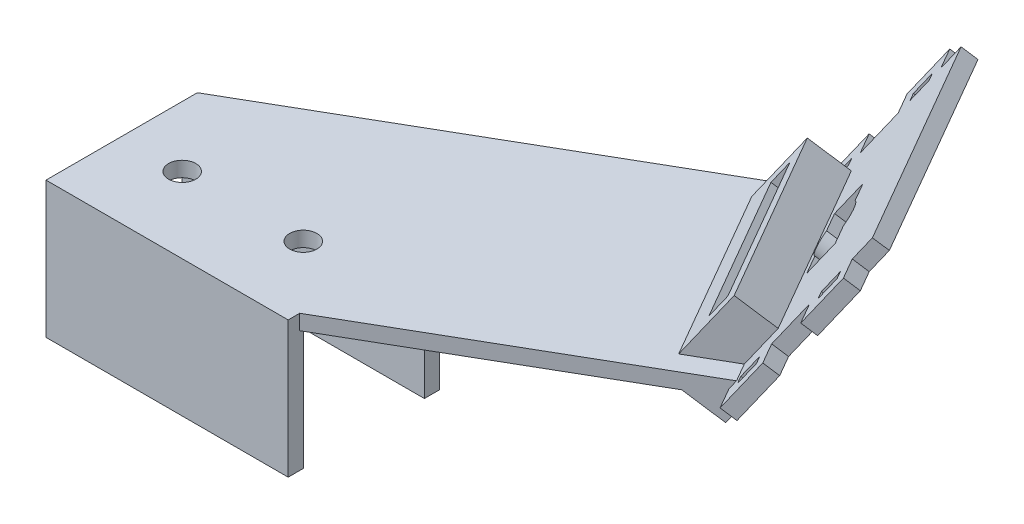
from build123d import *

# Parameters (mm, degrees)
BOSS_EXTRUDE1_DEPTH  = 50.8
SKETCH3_R            = 2.8575
CUT_EXTRUDE1_DEPTH   = 29.575
BOSS_EXTRUDE2_DEPTH  = 3.175
BOSS_EXTRUDE4_DEPTH  = 50.8
CUT_EXTRUDE2_REACH   = 108.711
BOSS_EXTRUDE5_DEPTH  = 8.255
BOSS_EXTRUDE6_REACH  = 116.966
CUT_EXTRUDE3_DEPTH   = 8.255
BOSS_EXTRUDE10_DEPTH = 3.175
BOSS_EXTRUDE11_DEPTH = 8.255
CUT_EXTRUDE4_START   = -11.43
CUT_EXTRUDE4_DEPTH   = 8.255
BOSS_EXTRUDE12_DEPTH = 4.445
CUT_EXTRUDE5_DEPTH   = 4.445
BOSS_EXTRUDE13_START = -50.8
BOSS_EXTRUDE13_DEPTH = 4.445
CUT_EXTRUDE6_START   = -50.8
CUT_EXTRUDE6_DEPTH   = 4.445
SKETCH18_R           = 5.08
CUT_EXTRUDE7_DEPTH   = 55.801163899


with BuildPart() as part:
    # Sketch2 → Boss-Extrude1 (new body)
    with BuildSketch(Plane(origin=(0, 0, 0), x_dir=(0, 0, -1), z_dir=(1, 0, 0))):
        Polygon((0, 0), (31.75, 0), (31.75, -28.575), (28.575, -28.575), (28.575, -3.175), (3.175, -3.175), (3.175, -28.575), (0, -28.575), align=None)
    extrude(amount=BOSS_EXTRUDE1_DEPTH)

    # Sketch3 → Cut-Extrude1 (cut, through all)
    with BuildSketch(Plane(origin=(0, 0, 0), x_dir=(1, 0, 0), z_dir=(0, 1, 0))):
        with Locations((12.7, 15.875)):
            Circle(SKETCH3_R)
        with Locations((38.1, 15.875)):
            Circle(SKETCH3_R)
    extrude(amount=-CUT_EXTRUDE1_DEPTH, mode=Mode.SUBTRACT)

    # Sketch4 → Boss-Extrude2 (add)
    with BuildSketch(Plane(origin=(0, 0, 0), x_dir=(1, 0, 0), z_dir=(0, 1, 0))):
        Polygon((0, 31.75), (76.2, 75.744090512), (101.6, 31.75), (50.8, 2.420606325), (50.8, 31.75), align=None)
    extrude(amount=-BOSS_EXTRUDE2_DEPTH)

    # Sketch6 → Boss-Extrude4 (add)
    with BuildSketch(Plane(origin=(-13.748153285, 0, -23.8125), x_dir=(-0.866025404, 0, 0.5), z_dir=(-0.5, 0, -0.866025404))):
        Polygon((-103.863181024, -3.175), (-128.994432583, 32.716146821), (-126.393624843, 34.537252006), (-102.210380639, 0), (-103.863181024, 0), align=None)
    extrude(amount=-BOSS_EXTRUDE4_DEPTH)

    # Sketch7 → Cut-Extrude2 (cut, up to next)
    with BuildSketch(Plane(origin=(61.648020601, -49.844275413, -35.592501289), x_dir=(-0.318495595, 0.25751325, -0.91227599), z_dir=(0.70940648, -0.573576436, -0.409576022)), mode=Mode.PRIVATE) as cut_extrude2_sk1:
        Polygon((20.449889648, 80.334208308), (35.520058582, 75.3436539), (33.124592466, 68.109972811), (18.054423532, 73.100527219), align=None)
    cut_extrude2_tool1 = extrude(cut_extrude2_sk1.sketch, amount=-CUT_EXTRUDE2_REACH, mode=Mode.PRIVATE) & part.part
    add(cut_extrude2_tool1.solids().sort_by_distance((99.782151, 14.770573, -60.029858))[0], mode=Mode.SUBTRACT)
    # Sketch7 → Cut-Extrude2 (cut, up to next)
    with BuildSketch(Plane(origin=(61.648020601, -49.844275413, -35.592501289), x_dir=(-0.318495595, 0.25751325, -0.91227599), z_dir=(0.70940648, -0.573576436, -0.409576022)), mode=Mode.PRIVATE) as cut_extrude2_sk2:
        Polygon((7.213752471, 71.673620272), (40.970930883, 60.494778398), (39.373953472, 55.672324339), (5.61677506, 66.851166213), align=None)
    cut_extrude2_tool2 = extrude(cut_extrude2_sk2.sketch, amount=-CUT_EXTRUDE2_REACH, mode=Mode.PRIVATE) & part.part
    add(cut_extrude2_tool2.solids().sort_by_distance((94.262219, 5.667746, -56.842924))[0], mode=Mode.SUBTRACT)

    # Sketch8 → Boss-Extrude5 (add)
    with BuildSketch(Plane(origin=(61.648020601, -49.844275413, -35.592501289), x_dir=(-0.318495595, 0.25751325, -0.91227599), z_dir=(0.70940648, -0.573576436, -0.409576022))):
        Polygon((-4.21199432, 61.410144483), (44.012546269, 45.440370378), (57.786476434, 87.034036636), (9.561935845, 103.003810741), align=None)
        Polygon((11.577858751, 98.991666073), (-0.199849652, 63.426067388), (41.996623363, 49.452515046), (53.774331766, 85.018113731), align=None, mode=Mode.SUBTRACT)
    extrude(amount=BOSS_EXTRUDE5_DEPTH)

    # Boss-Extrude6: up to this face of the body (flat: up to its plane)
    boss_extrude6_end = Plane(part.part.faces().sort_by_distance((50.815624122, -3.175, -33.129894289))[0])
    # Sketch9 → Boss-Extrude6 (add, up to the picked face)
    with BuildSketch(Plane(origin=(67.504171093, -54.579148895, -38.973551352), x_dir=(-0.318495595, 0.25751325, -0.91227599), z_dir=(0.70940648, -0.573576436, -0.409576022)), mode=Mode.PRIVATE) as boss_extrude6_sk1:
        Polygon((0.007652981, 60.012789249), (39.792898967, 46.837725612), (38.994410262, 44.426498583), (-0.790835724, 57.601562219), align=None)
    boss_extrude6_tool1 = split(extrude(boss_extrude6_sk1.sketch, amount=-BOSS_EXTRUDE6_REACH, mode=Mode.PRIVATE), bisect_by=boss_extrude6_end, keep=Keep.BOTH, mode=Mode.PRIVATE)
    add(boss_extrude6_tool1.solids().sort_by_distance((94.125301, -8.950197, -56.763874))[0])

    # Sketch10 → Cut-Extrude3 (cut)
    with BuildSketch(Plane(origin=(67.504171093, -54.579148895, -38.973551352), x_dir=(-0.318495595, 0.25751325, -0.91227599), z_dir=(0.70940648, -0.573576436, -0.409576022))):
        Polygon((4.019797649, 62.028712154), (37.776976062, 50.84987028), (36.978487357, 48.438643251), (3.221308944, 59.617485125), align=None)
    extrude(amount=-CUT_EXTRUDE3_DEPTH, mode=Mode.SUBTRACT)

    # Sketch14 → Boss-Extrude10 (add)
    with BuildSketch(Plane(origin=(67.504171093, -54.579148895, -38.973551352), x_dir=(-0.318495595, 0.25751325, -0.91227599), z_dir=(0.70940648, -0.573576436, -0.409576022))):
        Polygon((-2.515205822, 66.534001921), (-7.337659881, 68.130979331), (-3.744460707, 78.981500964), (1.077993352, 77.384523553), (0.07988247, 74.370489766), (-1.728537802, 74.969356295), (-3.325515212, 70.146902236), (-1.51709494, 69.548035707), align=None)
        Polygon((5.058616193, 95.464786046), (6.867036465, 94.865919517), (7.865147347, 97.879953304), (3.042693288, 99.476930714), (-0.550505886, 88.626409082), (4.271948173, 87.029431671), (5.270059055, 90.043465458), (3.461638782, 90.642331987), align=None)
        Polygon((55.303019916, 73.474824824), (56.899997326, 78.297278883), (55.091577054, 78.896145411), (56.089687936, 81.910179198), (60.912141995, 80.313201788), (57.318942821, 69.462680155), (52.496488762, 71.059657566), (53.494599644, 74.073691353), align=None)
        Polygon((48.515865921, 52.979395073), (46.707445649, 53.578261602), (45.709334767, 50.564227815), (50.531788826, 48.967250405), (54.124988, 59.817772037), (49.302533941, 61.414749448), (48.304423059, 58.400715661), (50.112843331, 57.801849132), align=None)
    extrude(amount=-BOSS_EXTRUDE10_DEPTH)

    # Sketch15 → Boss-Extrude11 (add)
    with BuildSketch(Plane(origin=(61.648020601, -49.844275413, -35.592501289), x_dir=(-0.318495595, 0.25751325, -0.91227599), z_dir=(0.70940648, -0.573576436, -0.409576022))):
        Polygon((4.019797649, 62.028712154), (7.213752471, 71.673620272), (40.970930883, 60.494778398), (37.776976062, 50.84987028), (41.996623363, 49.452515046), (53.774331766, 85.018113731), (11.577858751, 98.991666073), (-0.199849652, 63.426067388), align=None)
        Polygon((20.449889648, 80.334208308), (35.520058582, 75.3436539), (33.124592466, 68.109972811), (18.054423532, 73.100527219), align=None, mode=Mode.SUBTRACT)
    extrude(amount=BOSS_EXTRUDE11_DEPTH)

    # Sketch16 → Cut-Extrude4 (cut)
    with BuildSketch(Plane(origin=(67.504171093, -54.579148895, -38.973551352), x_dir=(-0.318495595, 0.25751325, -0.91227599), z_dir=(0.70940648, -0.573576436, -0.409576022)).offset(CUT_EXTRUDE4_START)):
        Polygon((9.561935845, 103.003810741), (-3.213883439, 64.42417827), (1.005763863, 63.026823036), (5.197829565, 75.68576494), (44.983075551, 62.510701303), (40.791009849, 49.851759399), (45.01065715, 48.454404165), (57.786476434, 87.034036636), align=None)
    extrude(amount=CUT_EXTRUDE4_DEPTH, mode=Mode.SUBTRACT)

    # Sketch17 → Boss-Extrude12 (add)
    with BuildSketch(Plane(origin=(11.651846715, 0, 20.181590512), x_dir=(0.866025404, 0, -0.5), z_dir=(0.5, 0, 0.866025404))):
        Polygon((111.120352225, -1.667395138), (112.287874869, 0), (104.864254679, 0), (109.845578595, -3.487960556), align=None)
    extrude(amount=-BOSS_EXTRUDE12_DEPTH)

    # Sketch17_3 → Cut-Extrude5 (cut)
    with BuildSketch(Plane(origin=(11.651846715, 0, 20.181590512), x_dir=(0.866025404, 0, -0.5), z_dir=(0.5, 0, 0.866025404))):
        Polygon((102.210380639, 0), (104.864254679, 0), (103.083478469, 1.246912926), align=None)
    extrude(amount=-CUT_EXTRUDE5_DEPTH, mode=Mode.SUBTRACT)

    # Sketch17_4 → Boss-Extrude13 (add)
    with BuildSketch(Plane(origin=(11.651846715, 0, 20.181590512), x_dir=(0.866025404, 0, -0.5), z_dir=(0.5, 0, 0.866025404)).offset(BOSS_EXTRUDE13_START)):
        Polygon((111.120352225, -1.667395138), (112.287874869, 0), (104.864254679, 0), (109.845578595, -3.487960556), align=None)
    extrude(amount=BOSS_EXTRUDE13_DEPTH)

    # Sketch17_5 → Cut-Extrude6 (cut)
    with BuildSketch(Plane(origin=(11.651846715, 0, 20.181590512), x_dir=(0.866025404, 0, -0.5), z_dir=(0.5, 0, 0.866025404)).offset(CUT_EXTRUDE6_START)):
        Polygon((102.210380639, 0), (104.864254679, 0), (103.083478469, 1.246912926), align=None)
    extrude(amount=CUT_EXTRUDE6_DEPTH, mode=Mode.SUBTRACT)

    # Sketch18 → Cut-Extrude7 (cut, through all)
    with BuildSketch(Plane(origin=(65.251805519, -52.758043709, -37.673147481), x_dir=(0.318495595, -0.25751325, 0.91227599), z_dir=(-0.70940648, 0.573576436, 0.409576022))):
        with Locations((-26.787241057, 74.222090559)):
            Circle(SKETCH18_R)
    extrude(amount=-CUT_EXTRUDE7_DEPTH, mode=Mode.SUBTRACT)


solid = part.part
